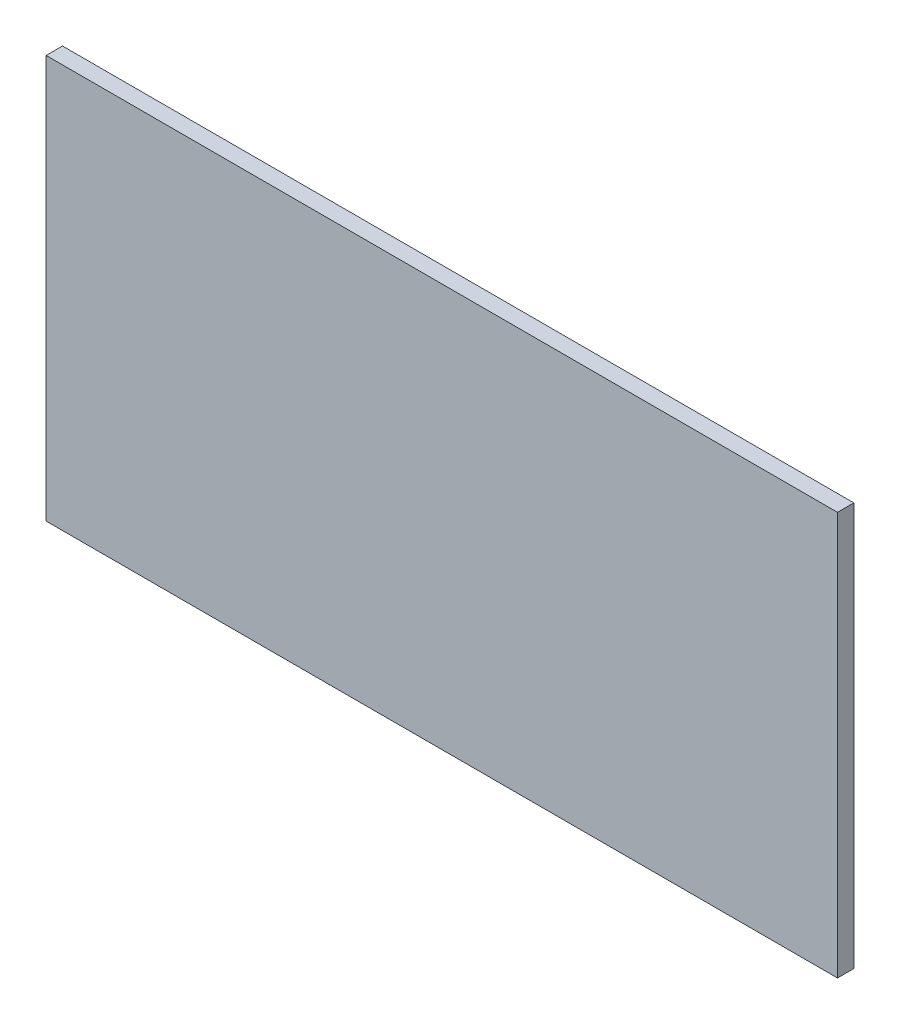
from build123d import *

# Parameters (mm, degrees)
SKETCH1_W           = 576.2625
SKETCH1_H           = 293.6875
BOSS_EXTRUDE1_DEPTH = 11.90625


with BuildPart() as part:
    # Sketch1 → Boss-Extrude1 (new body)
    with BuildSketch(Plane.XY):
        with Locations((82.067862533, -69.746431816)):
            Rectangle(SKETCH1_W, SKETCH1_H)
    extrude(amount=BOSS_EXTRUDE1_DEPTH)


solid = part.part
